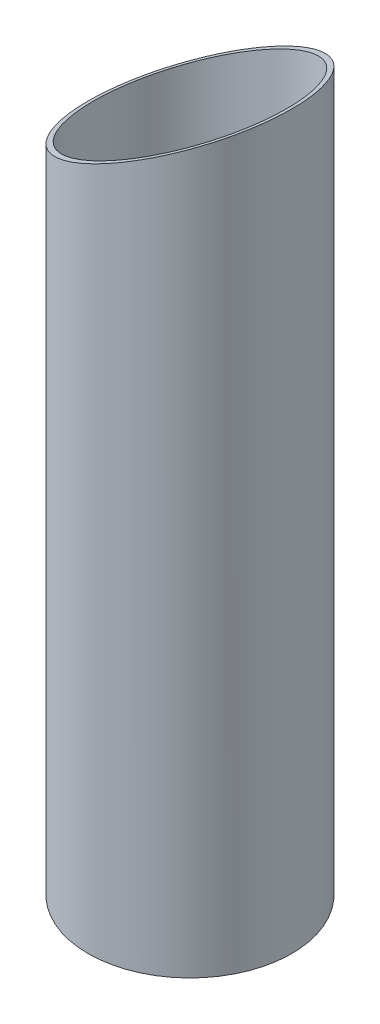
from build123d import *

# Parameters (mm, degrees)
ESQUISSE1_R                  = 40
ESQUISSE1_R_2                = 38
BOSS_EXTRU_1_DEPTH           = 300
ENL_V_MAT_EXTRU_1_DEPTH      = 50
ENL_V_MAT_EXTRU_1_DEPTH_BACK = 50


with BuildPart() as part:
    # Esquisse1 → Boss.-Extru.1 (new body)
    with BuildSketch(Plane(origin=(0, 0, 0), x_dir=(1, 0, 0), z_dir=(0, 1, 0))):
        with Locations(Location((0, 0, 0), (0, 0, 270))):  # turned: the seam where the file's is
            Circle(ESQUISSE1_R)
        with Locations(Location((0, 0, 0), (0, 0, 270))):  # turned: the seam where the file's is
            Circle(ESQUISSE1_R_2, mode=Mode.SUBTRACT)
    extrude(amount=BOSS_EXTRU_1_DEPTH)

    # Esquisse2 → Enl_v. mat.-Extru.1 (cut, two sides)
    with BuildSketch(Plane.XY) as enl_v_mat_extru_1_sk:
        Polygon((50.630778704, 292.261826174), (50.630778704, 339.972183494), (-60.713064901, 339.972183494), (-60.713064901, 240.341339213), align=None)
    extrude(amount=ENL_V_MAT_EXTRU_1_DEPTH, mode=Mode.SUBTRACT)
    extrude(enl_v_mat_extru_1_sk.sketch, amount=-ENL_V_MAT_EXTRU_1_DEPTH_BACK, mode=Mode.SUBTRACT)


solid = part.part
